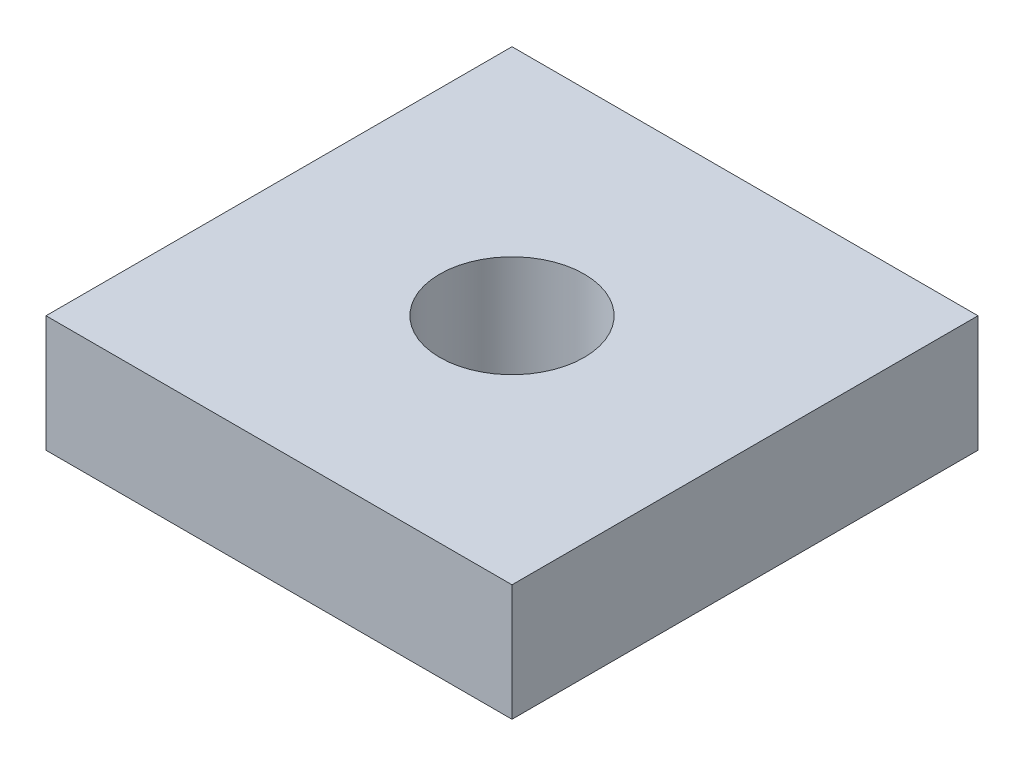
from build123d import *

# Parameters (mm, degrees)
SKETCH1_W           = 50.8
SKETCH1_H           = 50.8
SKETCH1_R           = 7.874
BOSS_EXTRUDE1_DEPTH = 12.7


with BuildPart() as part:
    # Sketch1 → Boss-Extrude1 (new body)
    with BuildSketch(Plane(origin=(0, 0, 0), x_dir=(1, 0, 0), z_dir=(0, 1, 0))):
        with Locations((25.4, 25.4)):
            Rectangle(SKETCH1_W, SKETCH1_H)
        with Locations((25.4, 25.4)):
            Circle(SKETCH1_R, mode=Mode.SUBTRACT)
    extrude(amount=BOSS_EXTRUDE1_DEPTH)


solid = part.part
